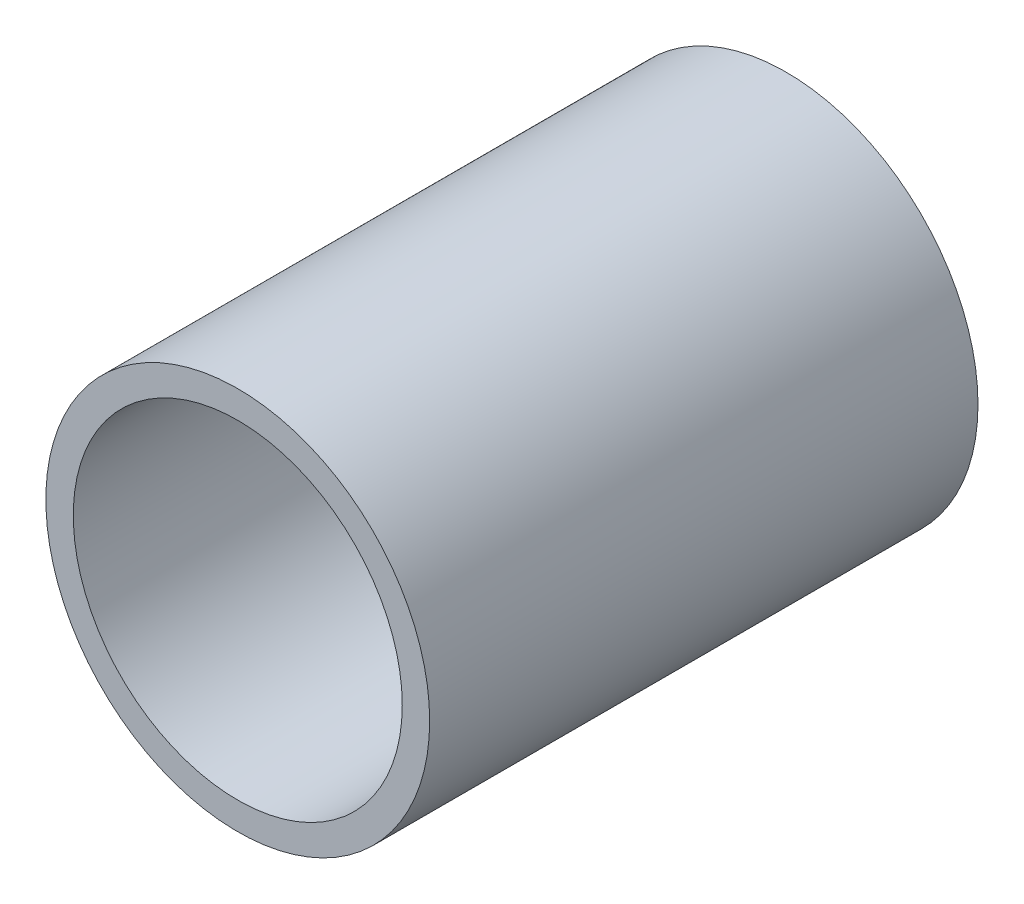
from build123d import *

# Parameters (mm, degrees)
SKETCH1_R           = 70
SKETCH1_R_2         = 60
BOSS_EXTRUDE1_DEPTH = 200


with BuildPart() as part:
    # Sketch1 → Boss-Extrude1 (new body)
    with BuildSketch(Plane.XY):
        Circle(SKETCH1_R)
        Circle(SKETCH1_R_2, mode=Mode.SUBTRACT)
    extrude(amount=BOSS_EXTRUDE1_DEPTH)


solid = part.part
